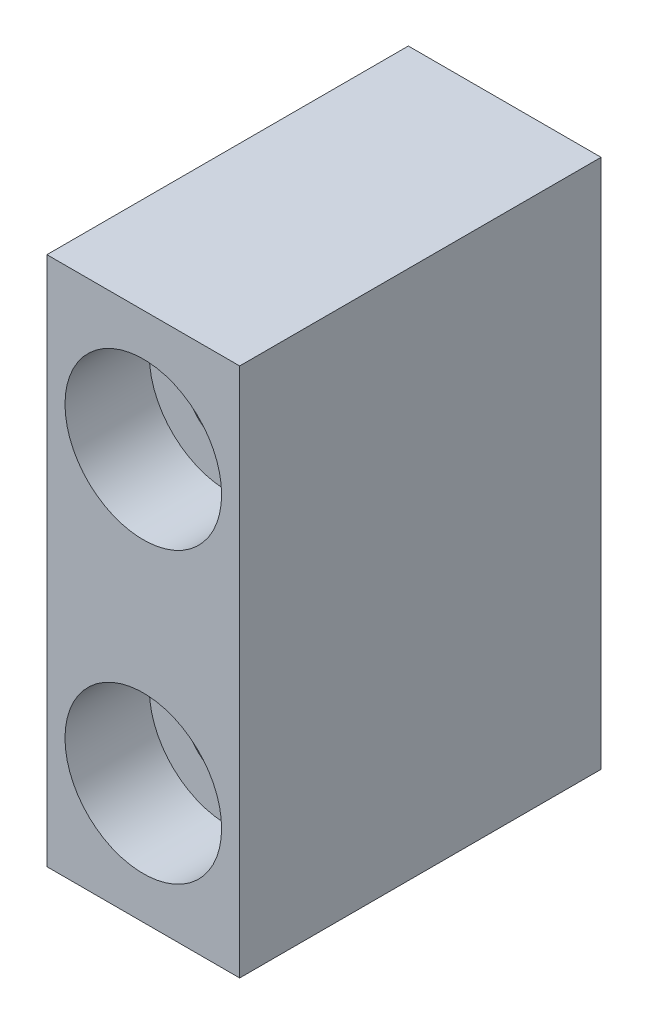
from build123d import *

# Parameters (mm, degrees)
SKETCH1_W           = 8
SKETCH1_H           = 22
BOSS_EXTRUDE1_DEPTH = 15
SKETCH2_R           = 1.75
CUT_EXTRUDE1_DEPTH  = 16
SKETCH3_R           = 3.25
CUT_EXTRUDE2_DEPTH  = 3.5


with BuildPart() as part:
    # Sketch1 → Boss-Extrude1 (new body)
    with BuildSketch(Plane.XY):
        with Locations((-4, -3.701030928)):
            Rectangle(SKETCH1_W, SKETCH1_H)
    extrude(amount=BOSS_EXTRUDE1_DEPTH)

    # Sketch2 → Cut-Extrude1 (cut, through all)
    with BuildSketch(Plane.XY.offset(15)):
        with Locations((-4, 2.298969072)):
            Circle(SKETCH2_R)
        with Locations((-4, -9.701030928)):
            Circle(SKETCH2_R)
    extrude(amount=-CUT_EXTRUDE1_DEPTH, mode=Mode.SUBTRACT)

    # Sketch3 → Cut-Extrude2 (cut)
    with BuildSketch(Plane.XY.offset(15)):
        with Locations((-4, 2.298969072)):
            Circle(SKETCH3_R)
        with Locations((-4, -9.701030928)):
            Circle(SKETCH3_R)
    extrude(amount=-CUT_EXTRUDE2_DEPTH, mode=Mode.SUBTRACT)


solid = part.part
